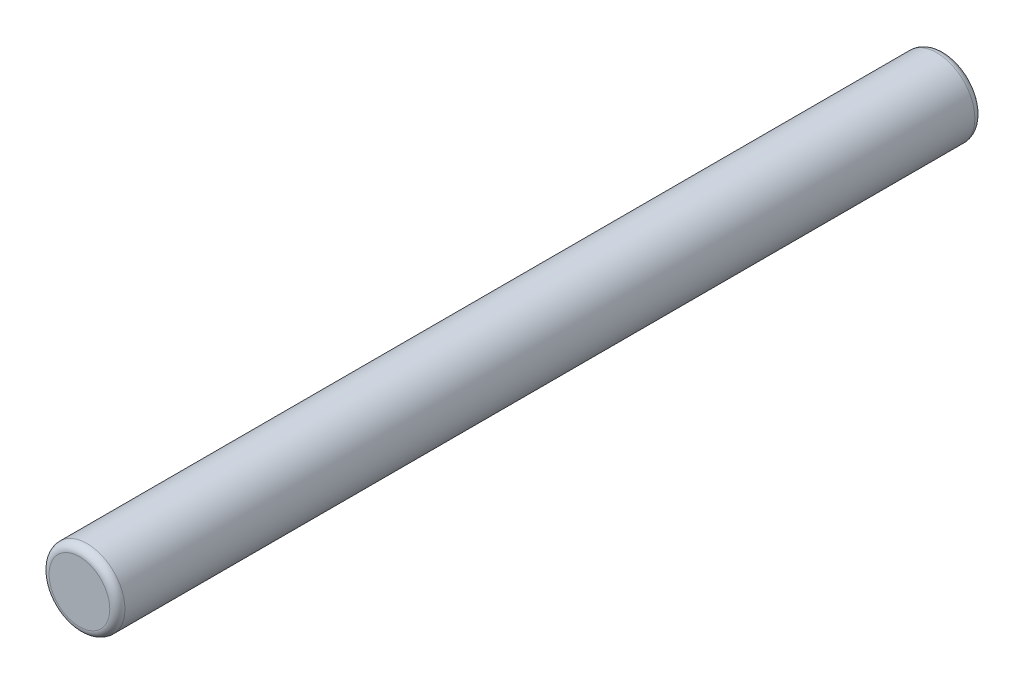
from build123d import *

# Parameters (mm, degrees)
SKETCH1_R           = 2.5
BOSS_EXTRUDE1_DEPTH = 57
FILLET2_R           = 0.5
FILLET3_R           = 0.5


with BuildPart() as part:
    # Sketch1 → Boss-Extrude1 (new body)
    with BuildSketch(Plane.XY):
        Circle(SKETCH1_R)
    extrude(amount=BOSS_EXTRUDE1_DEPTH)

    # Fillet2
    fillet2_edges = [part.edges().sort_by_distance(p)[0] for p in [
        (-2.5, 0, 0),
    ]]
    fillet(fillet2_edges, radius=FILLET2_R)

    # Fillet3
    fillet3_edges = [part.edges().sort_by_distance(p)[0] for p in [
        (-2.5, 0, 57),
    ]]
    fillet(fillet3_edges, radius=FILLET3_R)


solid = part.part
